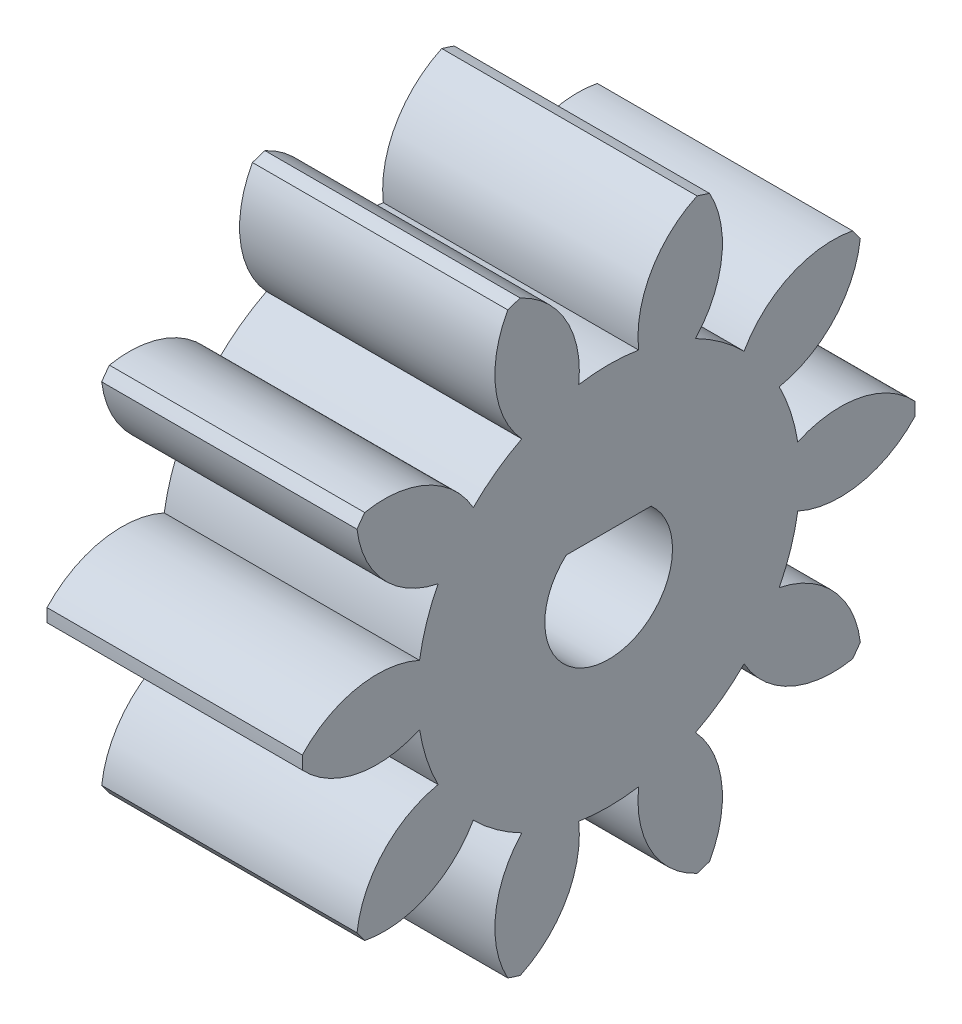
from build123d import *

# Parameters (mm, degrees)
BASPROSKE_W         = 10
BASPROSKE_H         = 12
TOOTHCUT_DEPTH      = 20.697715604
TEETHCUTS_COUNT     = 10
TEETHCUTS_ANGLE     = 324
BORSKE_R            = 2.5
BORE_DEPTH          = 50.0000508
BOSS_EXTRUDE1_DEPTH = 10


with BuildPart() as part:
    # BasProSke → Base-Revolve (revolve)
    with BuildSketch(Plane(origin=(0, 0, 0), x_dir=(1, 0, 0), z_dir=(0, 1, 0)), mode=Mode.PRIVATE) as base_revolve_sk:
        with Locations((5, 6)):
            Rectangle(BASPROSKE_W, BASPROSKE_H)
    revolve(base_revolve_sk.sketch.rotate(Axis((-10, 0, 0), (1, 0, 0)), 180), axis=Axis((-10, 0, 0), (1, 0, 0)))

    # TooCutSke → ToothCut (cut, through all)
    with BuildSketch(Plane(origin=(0, 0, 0), x_dir=(0, 0, -1), z_dir=(1, 0, 0))):
        with BuildLine():
            ThreePointArc((1.173662691, 7.406586048), (0, 7.499), (-1.173662691, 7.406586048))
            ThreePointArc((-1.173662691, 7.406586048), (-1.668191438, 9.834565786), (-3.497907776, 11.50542856))
            ThreePointArc((-3.497907776, 11.50542856), (0, 12.0254), (3.497907776, 11.50542856))
            ThreePointArc((3.497907776, 11.50542856), (1.668191438, 9.834565786), (1.173662691, 7.406586048))
        make_face()
    toothcut = extrude(amount=TOOTHCUT_DEPTH, mode=Mode.SUBTRACT)

    # TeethCuts: ToothCut ×10 about axis
    teethcuts_axis = Axis((-10, 0, 0), (1, 0, 0))
    for i in range(1, TEETHCUTS_COUNT):
        add(toothcut.rotate(teethcuts_axis, i * TEETHCUTS_ANGLE / (TEETHCUTS_COUNT - 1)), mode=Mode.SUBTRACT)

    # BorSke → Bore (cut, symmetric)
    with BuildSketch(Plane(origin=(0, 0, 0), x_dir=(0, 0, -1), z_dir=(1, 0, 0))):
        with Locations(Location((0, 0, 0), (0, 0, 180))):
            Circle(BORSKE_R)
    extrude(amount=BORE_DEPTH, both=True, mode=Mode.SUBTRACT)

    # Sketch1 → Boss-Extrude1 (add)
    with BuildSketch(Plane(origin=(10, 0, 0), x_dir=(0, 0, -1), z_dir=(1, 0, 0))):
        with BuildLine():
            Line((-1.660598254, 1.8688), (1.660598254, 1.8688))
            ThreePointArc((1.660598254, 1.8688), (0, 2.5), (-1.660598254, 1.8688))
        make_face()
    extrude(amount=-BOSS_EXTRUDE1_DEPTH)


solid = part.part
